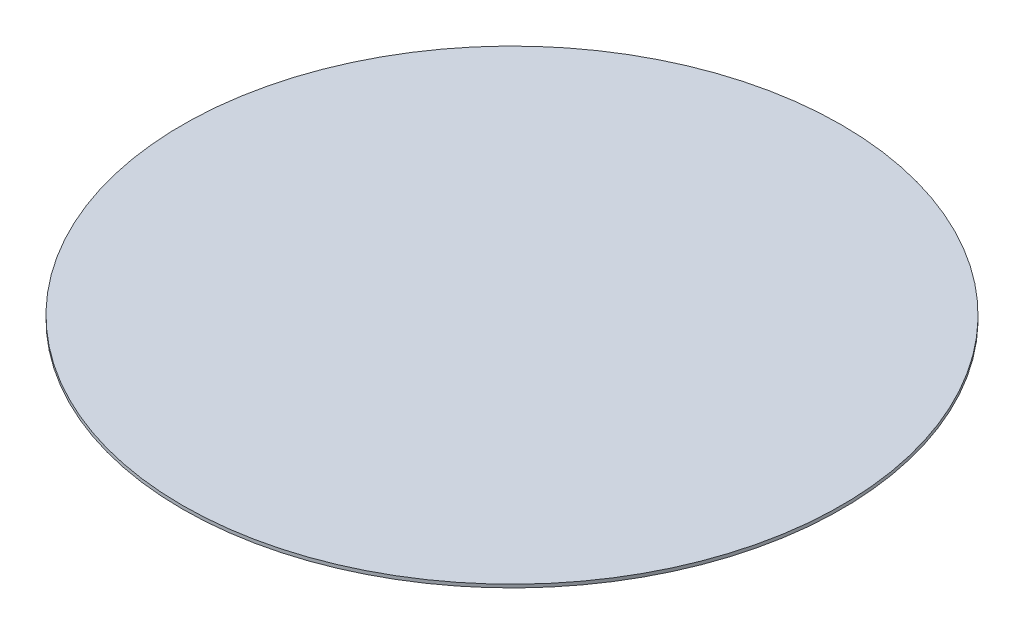
from build123d import *

# Parameters (mm, degrees)
SKETCH1_R           = 25.81275
BOSS_EXTRUDE1_DEPTH = 0.254


with BuildPart() as part:
    # Sketch1 → Boss-Extrude1 (new body)
    with BuildSketch(Plane(origin=(0, 0, 0), x_dir=(1, 0, 0), z_dir=(0, 1, 0))):
        Circle(SKETCH1_R)
    extrude(amount=BOSS_EXTRUDE1_DEPTH)


solid = part.part
